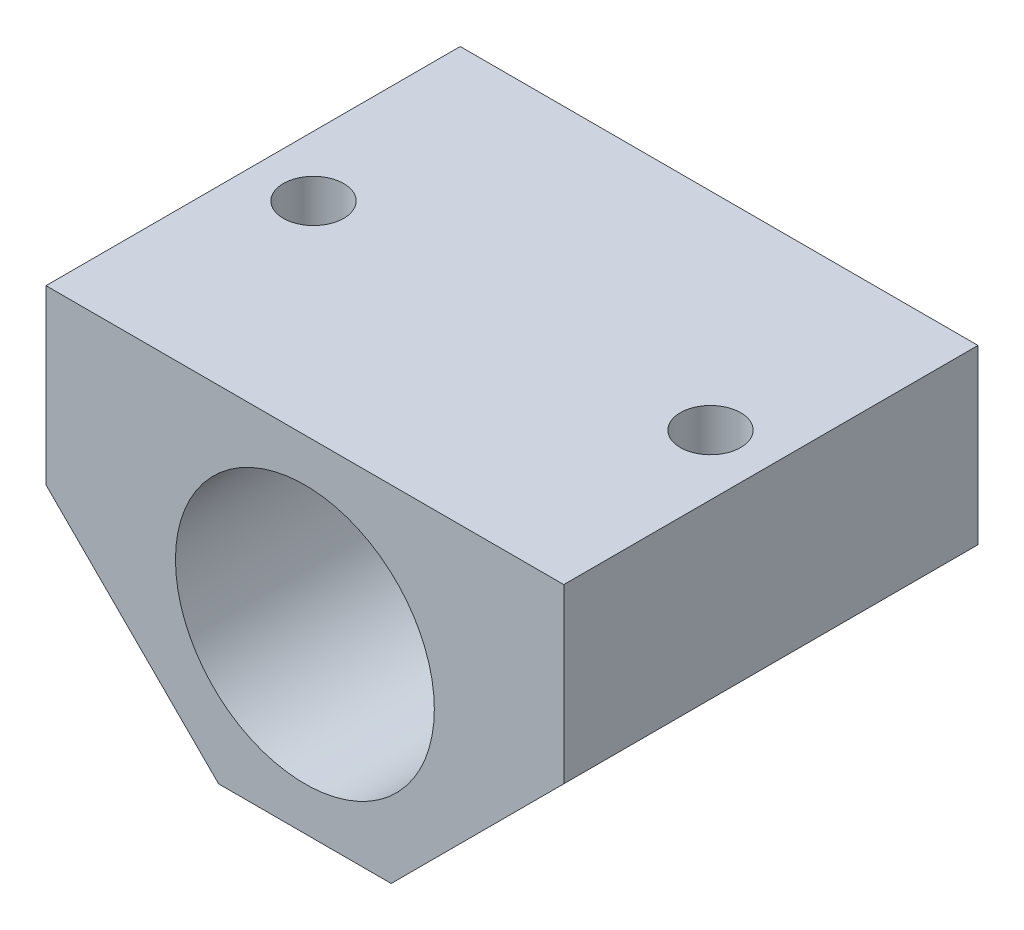
from build123d import *

# Parameters (mm, degrees)
SKETCH1_R           = 7.5
BOSS_EXTRUDE1_DEPTH = 24
SKETCH2_R           = 1.75
CUT_EXTRUDE1_DEPTH  = 24
CUT_EXTRUDE2_START  = -10
CUT_EXTRUDE2_DEPTH  = 7


with BuildPart() as part:
    # Sketch1 → Boss-Extrude1 (new body)
    with BuildSketch(Plane.XY):
        Polygon((0, 10), (0, 0), (-10, -10), (-20, -10), (-30, 0), (-30, 10), align=None)
        with Locations((-15, 0)):
            Circle(SKETCH1_R, mode=Mode.SUBTRACT)
    extrude(amount=BOSS_EXTRUDE1_DEPTH)

    # Sketch2 → Cut-Extrude1 (cut)
    with BuildSketch(Plane(origin=(0, 10, 0), x_dir=(1, 0, 0), z_dir=(0, 1, 0))):
        with Locations((-26.5, -12)):
            Circle(SKETCH2_R)
        with Locations((-3.5, -12)):
            Circle(SKETCH2_R)
    extrude(amount=-CUT_EXTRUDE1_DEPTH, mode=Mode.SUBTRACT)

    # Sketch4 → Cut-Extrude2 (cut)
    with BuildSketch(Plane(origin=(0, 10, 0), x_dir=(1, 0, 0), z_dir=(0, 1, 0)).offset(CUT_EXTRUDE2_START)):
        Polygon((-3.5, -15.175426481), (-0.75, -13.58771324), (-0.75, -10.41228676), (-3.5, -8.824573519), (-6.25, -10.41228676), (-6.25, -13.58771324), align=None)
        Polygon((-26.5, -15.175426481), (-23.75, -13.58771324), (-23.75, -10.41228676), (-26.5, -8.824573519), (-29.25, -10.41228676), (-29.25, -13.58771324), align=None)
    extrude(amount=-CUT_EXTRUDE2_DEPTH, mode=Mode.SUBTRACT)


solid = part.part
